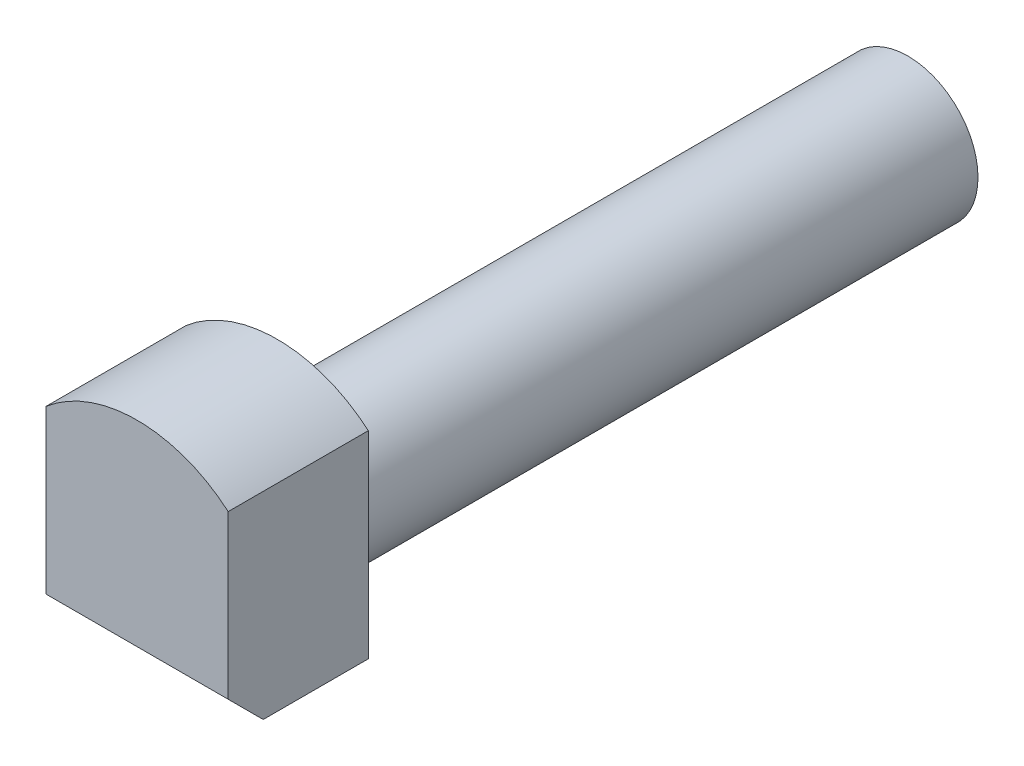
from build123d import *

# Parameters (mm, degrees)
ESQUISSE1_R                  = 1
BOSS_EXTRU_1_DEPTH           = 3.5
BOSS_EXTRU_1_DEPTH_BACK      = 11
ESQUISSE2_R                  = 2
BOSS_EXTRU_2_DEPTH           = 2
ESQUISSE3_OUTSIDE_W          = 9.488
ESQUISSE3_OUTSIDE_H          = 9.488
ENL_V_MAT_EXTRU_1_DEPTH      = 1
ENL_V_MAT_EXTRU_1_DEPTH_BACK = 17.5
CHANFREIN1_SIZE              = 0.5
ESQUISSE4_R                  = 1
ENL_V_MAT_EXTRU_2_DEPTH      = 5.5


with BuildPart() as part:
    # Esquisse1 → Boss.-Extru.1 (new body, two sides)
    with BuildSketch(Plane.XY) as boss_extru_1_sk:
        with Locations((2.7, 1.35)):
            Circle(ESQUISSE1_R)
    extrude(amount=BOSS_EXTRU_1_DEPTH)
    extrude(boss_extru_1_sk.sketch, amount=-BOSS_EXTRU_1_DEPTH_BACK)

    # Esquisse2 → Boss.-Extru.2 (add)
    with BuildSketch(Plane.XY.offset(3.5)):
        with Locations((2.7, 1.35)):
            Circle(ESQUISSE2_R)
    extrude(amount=BOSS_EXTRU_2_DEPTH)

    # Esquisse3 outside → Enlèv. mat.-Extru.1 (cut, two sides)
    with BuildSketch(Plane.XY.offset(5.5)) as enl_v_mat_extru_1_sk:
        with Locations((2.7, 1.35)):
            Rectangle(ESQUISSE3_OUTSIDE_W, ESQUISSE3_OUTSIDE_H)
        with BuildLine():
            Line((1.4, 2.869868415), (1.4, 0.05))
            Line((1.4, 0.05), (4, 0.05))
            Line((4, 0.05), (4, 2.869868415))
            ThreePointArc((4, 2.869868415), (2.7, 3.35), (1.4, 2.869868415))
        make_face(mode=Mode.SUBTRACT)
    extrude(amount=ENL_V_MAT_EXTRU_1_DEPTH, mode=Mode.SUBTRACT)
    extrude(enl_v_mat_extru_1_sk.sketch, amount=-ENL_V_MAT_EXTRU_1_DEPTH_BACK, mode=Mode.SUBTRACT)

    # Chanfrein1
    chanfrein1_edges = [part.edges().sort_by_distance(p)[0] for p in [
        (2.7, 0.05, 5.5),
    ]]
    chamfer(chanfrein1_edges, length=CHANFREIN1_SIZE)

    # Esquisse4 → Enlèv. mat.-Extru.2 (cut)
    with BuildSketch(Plane(origin=(0, 0, -11), x_dir=(-1, 0, 0), z_dir=(0, 0, -1))):
        with Locations((-2.7, 1.35)):
            Circle(ESQUISSE4_R)
    extrude(amount=-ENL_V_MAT_EXTRU_2_DEPTH, mode=Mode.SUBTRACT)


solid = part.part
